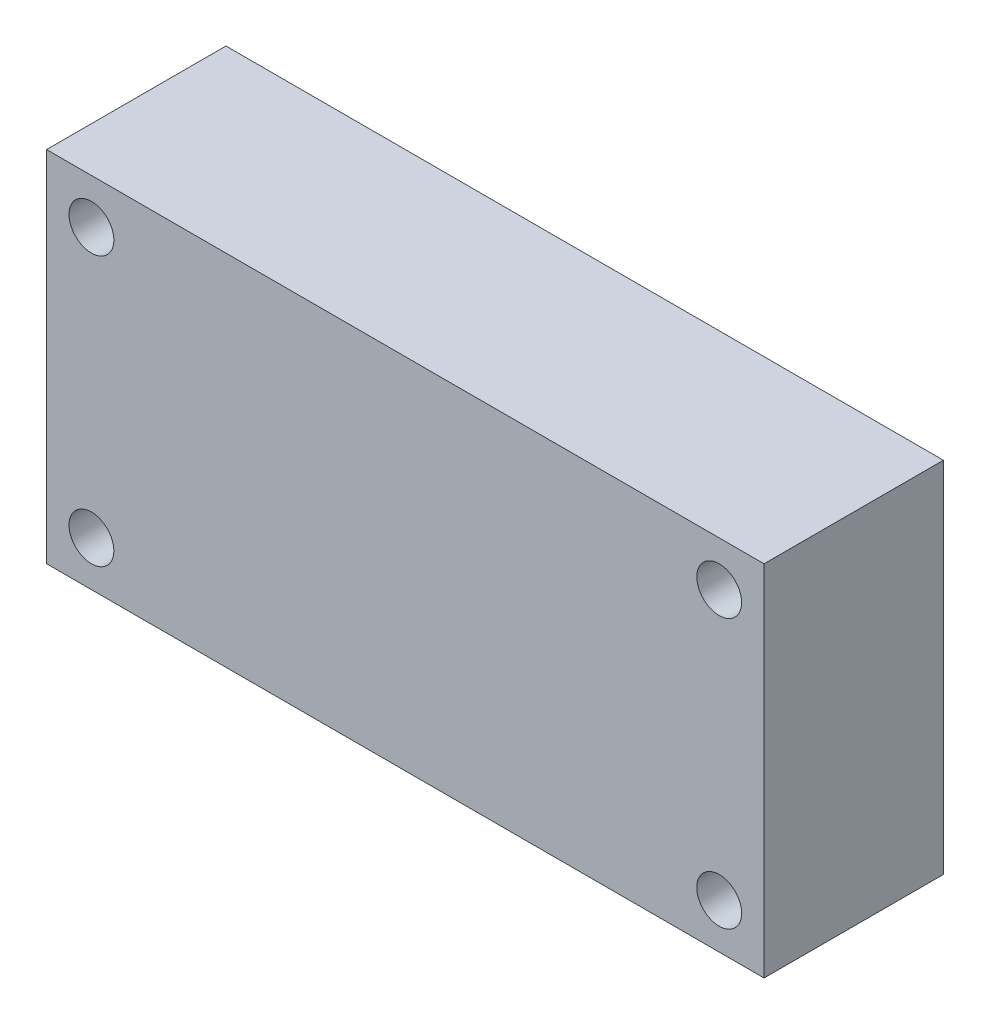
from build123d import *

# Parameters (mm, degrees)
CROQUIS1_W              = 101.6
CROQUIS1_H              = 50.8
CROQUIS1_R              = 3.175
SALIENTE_EXTRUIR1_DEPTH = 25.4


with BuildPart() as part:
    # Croquis1 → Saliente-Extruir1 (new body)
    with BuildSketch(Plane.XY):
        Rectangle(CROQUIS1_W, CROQUIS1_H)
        with Locations((44.45, 19.05)):
            Circle(CROQUIS1_R, mode=Mode.SUBTRACT)
        with Locations((-44.45, -19.05)):
            Circle(CROQUIS1_R, mode=Mode.SUBTRACT)
        with Locations((-44.45, 19.05)):
            Circle(CROQUIS1_R, mode=Mode.SUBTRACT)
        with Locations((44.45, -19.05)):
            Circle(CROQUIS1_R, mode=Mode.SUBTRACT)
    extrude(amount=-SALIENTE_EXTRUIR1_DEPTH)


solid = part.part
